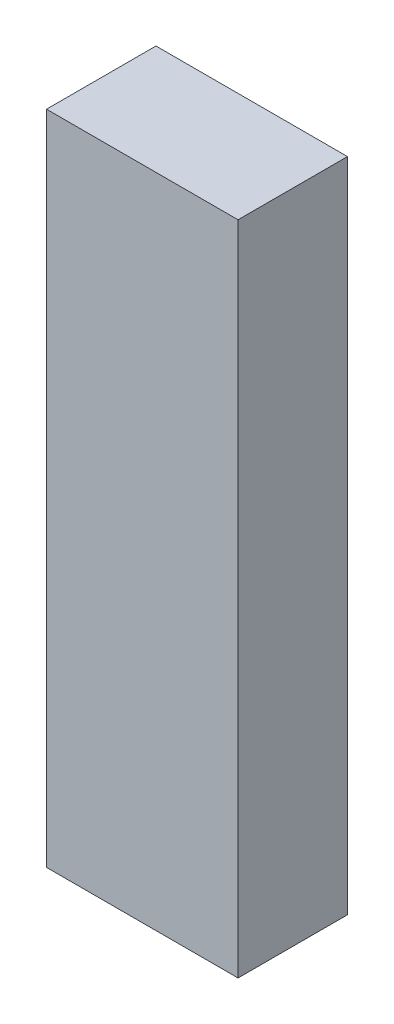
from build123d import *

# Parameters (mm, degrees)
SKETCH1_W           = 14
SKETCH1_H           = 48
BOSS_EXTRUDE1_DEPTH = 4


with BuildPart() as part:
    # Sketch1 → Boss-Extrude1 (new body, symmetric)
    with BuildSketch(Plane.XY):
        Rectangle(SKETCH1_W, SKETCH1_H)
    extrude(amount=BOSS_EXTRUDE1_DEPTH, both=True)


solid = part.part
